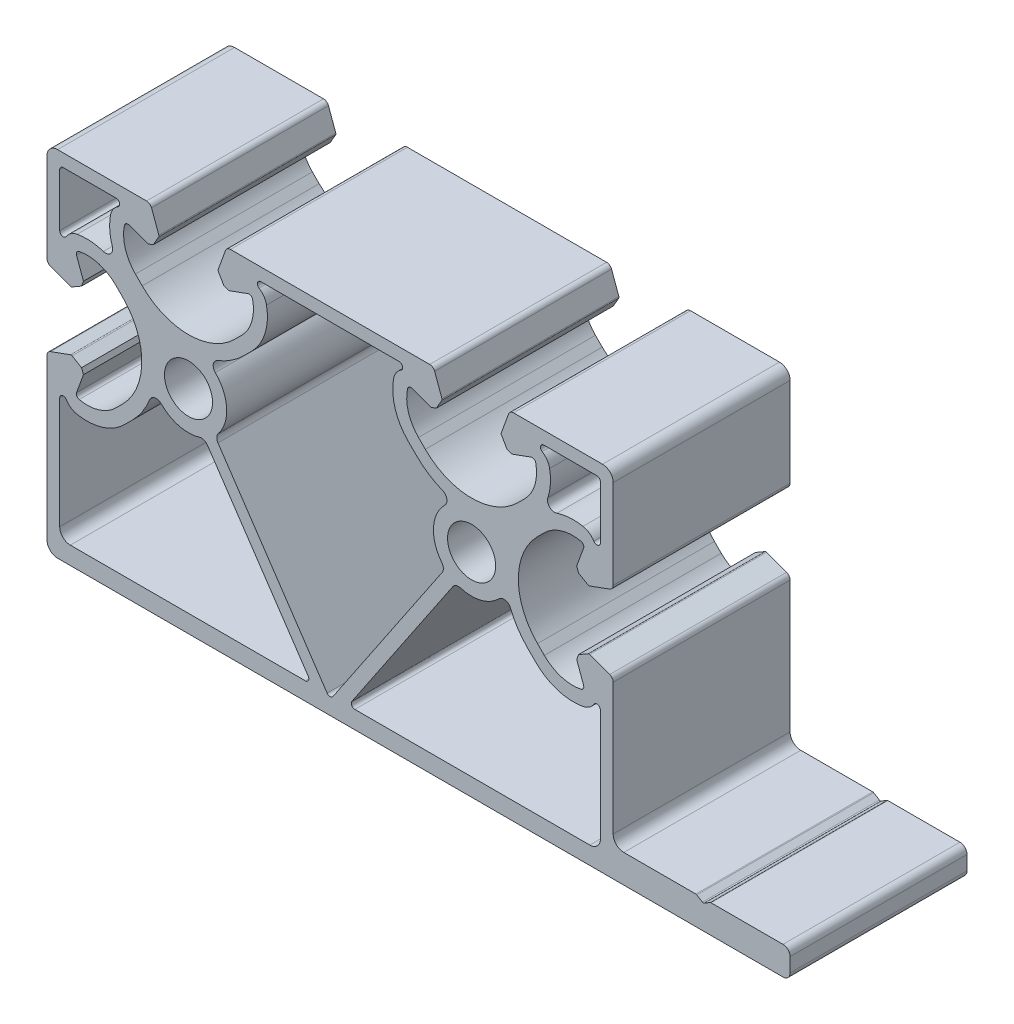
from build123d import *

# Parameters (mm, degrees)
SK_MAIN_EXTRUSION_R  = 3.4
MAIN_EXTRUSION_DEPTH = 25


with BuildPart() as part:
    # Sk Main Extrusion → Main Extrusion (new body)
    with BuildSketch(Plane.XY):
        with BuildLine():
            Line((-36.671180212, 25.809923155), (-39.506515107, 24.777945649))
            ThreePointArc((-39.506515107, 24.777945649), (-39.864364033, 24.503358511), (-40, 24.073176184))
            Line((-40, 24.073176184), (-40, 1.5))
            ThreePointArc((-40, 1.5), (-39.560660172, 0.439339828), (-38.5, 0))
            Line((-38.5, 0), (64, 0))
            ThreePointArc((64, 0), (64.707106781, 0.292893219), (65, 1))
            Line((65, 1), (65, 3))
            ThreePointArc((65, 3), (64.707106781, 3.707106781), (64, 4))
            Line((64, 4), (53.820658782, 4))
            ThreePointArc((53.820658782, 4), (53.753849188, 3.990907613), (53.691899263, 3.964291825))
            Line((53.691899263, 3.964291825), (52.878759519, 3.475708175))
            ThreePointArc((52.878759519, 3.475708175), (52.75, 3.44), (52.621240481, 3.475708175))
            Line((52.621240481, 3.475708175), (51.808100737, 3.964291825))
            ThreePointArc((51.808100737, 3.964291825), (51.746150812, 3.990907613), (51.679341218, 4))
            Line((51.679341218, 4), (41.5, 4))
            ThreePointArc((41.5, 4), (40.439339828, 4.439339828), (40, 5.5))
            Line((40, 5.5), (40, 24.073176184))
            ThreePointArc((40, 24.073176184), (39.864364033, 24.503358511), (39.506515107, 24.777945649))
            Line((39.506515107, 24.777945649), (36.671180212, 25.809923155))
            ThreePointArc((36.671180212, 25.809923155), (36.563886241, 25.824048675), (36.460675177, 25.791506351))
            Line((36.460675177, 25.791506351), (35.111296024, 25.012441934))
            Line((35.111296024, 25.012441934), (34.845251581, 24.281490834))
            Line((34.845251581, 24.281490834), (35.81984631, 21.603813821))
            ThreePointArc((35.81984631, 21.603813821), (35.786489799, 21.188925388), (35.450654467, 20.943039849))
            ThreePointArc((35.450654467, 20.943039849), (32.665882372, 21.066566987), (30.272684887, 22.495839661))
            Line((30.272684887, 22.495839661), (29.309262274, 23.459262274))
            ThreePointArc((29.309262274, 23.459262274), (26.6, 30), (29.309262274, 36.540737726))
            Line((29.309262274, 36.540737726), (30.272684887, 37.504160339))
            ThreePointArc((30.272684887, 37.504160339), (32.665882372, 38.933433013), (35.450654467, 39.056960151))
            ThreePointArc((35.450654467, 39.056960151), (35.786489799, 38.811074612), (35.81984631, 38.396186179))
            Line((35.81984631, 38.396186179), (34.845251581, 35.718509166))
            Line((34.845251581, 35.718509166), (35.111296024, 34.987558066))
            Line((35.111296024, 34.987558066), (36.460675177, 34.208493649))
            ThreePointArc((36.460675177, 34.208493649), (36.563886241, 34.175951325), (36.671180212, 34.190076845))
            Line((36.671180212, 34.190076845), (39.506515107, 35.222054351))
            ThreePointArc((39.506515107, 35.222054351), (39.864364033, 35.496641489), (40, 35.926823816))
            Line((40, 35.926823816), (40, 48.5))
            ThreePointArc((40, 48.5), (39.560660172, 49.560660172), (38.5, 50))
            Line((38.5, 50), (25.926823816, 50))
            ThreePointArc((25.926823816, 50), (25.496641489, 49.864364033), (25.222054351, 49.506515107))
            Line((25.222054351, 49.506515107), (24.190076845, 46.671180212))
            ThreePointArc((24.190076845, 46.671180212), (24.175951325, 46.563886241), (24.208493649, 46.460675177))
            Line((24.208493649, 46.460675177), (24.987558066, 45.111296024))
            Line((24.987558066, 45.111296024), (25.718509166, 44.845251581))
            Line((25.718509166, 44.845251581), (28.396186179, 45.81984631))
            ThreePointArc((28.396186179, 45.81984631), (28.811074612, 45.786489799), (29.056960151, 45.450654467))
            ThreePointArc((29.056960151, 45.450654467), (28.933433013, 42.665882372), (27.504160339, 40.272684887))
            Line((27.504160339, 40.272684887), (26.540737726, 39.309262274))
            ThreePointArc((26.540737726, 39.309262274), (20, 36.6), (13.459262274, 39.309262274))
            Line((13.459262274, 39.309262274), (12.495839661, 40.272684887))
            ThreePointArc((12.495839661, 40.272684887), (11.066566987, 42.665882372), (10.943039849, 45.450654467))
            ThreePointArc((10.943039849, 45.450654467), (11.188925388, 45.786489799), (11.603813821, 45.81984631))
            Line((11.603813821, 45.81984631), (14.281490834, 44.845251581))
            Line((14.281490834, 44.845251581), (15.012441934, 45.111296024))
            Line((15.012441934, 45.111296024), (15.791506351, 46.460675177))
            ThreePointArc((15.791506351, 46.460675177), (15.824048675, 46.563886241), (15.809923155, 46.671180212))
            Line((15.809923155, 46.671180212), (14.777945649, 49.506515107))
            ThreePointArc((14.777945649, 49.506515107), (14.503358511, 49.864364033), (14.073176184, 50))
            Line((14.073176184, 50), (-14.073176184, 50))
            ThreePointArc((-14.073176184, 50), (-14.503358511, 49.864364033), (-14.777945649, 49.506515107))
            Line((-14.777945649, 49.506515107), (-15.809923155, 46.671180212))
            ThreePointArc((-15.809923155, 46.671180212), (-15.824048675, 46.563886241), (-15.791506351, 46.460675177))
            Line((-15.791506351, 46.460675177), (-15.012441934, 45.111296024))
            Line((-15.012441934, 45.111296024), (-14.281490834, 44.845251581))
            Line((-14.281490834, 44.845251581), (-11.603813821, 45.81984631))
            ThreePointArc((-11.603813821, 45.81984631), (-11.188925388, 45.786489799), (-10.943039849, 45.450654467))
            ThreePointArc((-10.943039849, 45.450654467), (-11.066566987, 42.665882372), (-12.495839661, 40.272684887))
            Line((-12.495839661, 40.272684887), (-13.459262274, 39.309262274))
            ThreePointArc((-13.459262274, 39.309262274), (-20, 36.6), (-26.540737726, 39.309262274))
            Line((-26.540737726, 39.309262274), (-27.504160339, 40.272684887))
            ThreePointArc((-27.504160339, 40.272684887), (-28.933433013, 42.665882372), (-29.056960151, 45.450654467))
            ThreePointArc((-29.056960151, 45.450654467), (-28.811074612, 45.786489799), (-28.396186179, 45.81984631))
            Line((-28.396186179, 45.81984631), (-25.718509166, 44.845251581))
            Line((-25.718509166, 44.845251581), (-24.987558066, 45.111296024))
            Line((-24.987558066, 45.111296024), (-24.208493649, 46.460675177))
            ThreePointArc((-24.208493649, 46.460675177), (-24.175951325, 46.563886241), (-24.190076845, 46.671180212))
            Line((-24.190076845, 46.671180212), (-25.222054351, 49.506515107))
            ThreePointArc((-25.222054351, 49.506515107), (-25.496641489, 49.864364033), (-25.926823816, 50))
            Line((-25.926823816, 50), (-38.5, 50))
            ThreePointArc((-38.5, 50), (-39.560660172, 49.560660172), (-40, 48.5))
            Line((-40, 48.5), (-40, 35.926823816))
            ThreePointArc((-40, 35.926823816), (-39.864364033, 35.496641489), (-39.506515107, 35.222054351))
            Line((-39.506515107, 35.222054351), (-36.671180212, 34.190076845))
            ThreePointArc((-36.671180212, 34.190076845), (-36.563886241, 34.175951325), (-36.460675177, 34.208493649))
            Line((-36.460675177, 34.208493649), (-35.111296024, 34.987558066))
            Line((-35.111296024, 34.987558066), (-34.845251581, 35.718509166))
            Line((-34.845251581, 35.718509166), (-35.81984631, 38.396186179))
            ThreePointArc((-35.81984631, 38.396186179), (-35.786489799, 38.811074612), (-35.450654467, 39.056960151))
            ThreePointArc((-35.450654467, 39.056960151), (-32.665882372, 38.933433013), (-30.272684887, 37.504160339))
            Line((-30.272684887, 37.504160339), (-29.309262274, 36.540737726))
            ThreePointArc((-29.309262274, 36.540737726), (-26.6, 30), (-29.309262274, 23.459262274))
            Line((-29.309262274, 23.459262274), (-30.272684887, 22.495839661))
            ThreePointArc((-30.272684887, 22.495839661), (-32.665882372, 21.066566987), (-35.450654467, 20.943039849))
            ThreePointArc((-35.450654467, 20.943039849), (-35.786489799, 21.188925388), (-35.81984631, 21.603813821))
            Line((-35.81984631, 21.603813821), (-34.845251581, 24.281490834))
            Line((-34.845251581, 24.281490834), (-35.111296024, 25.012441934))
            Line((-35.111296024, 25.012441934), (-36.460675177, 25.791506351))
            ThreePointArc((-36.460675177, 25.791506351), (-36.563886241, 25.824048675), (-36.671180212, 25.809923155))
        make_face()
        with Locations((-20, 30)):
            Circle(SK_MAIN_EXTRUSION_R, mode=Mode.SUBTRACT)
        with Locations((20, 30)):
            Circle(SK_MAIN_EXTRUSION_R, mode=Mode.SUBTRACT)
        with BuildLine():
            Line((-11.050692158, 39.072247978), (-12.186470068, 37.936470068))
            ThreePointArc((-12.186470068, 37.936470068), (-13.91310246, 36.527626209), (-15.887298534, 35.493870777))
            ThreePointArc((-15.887298534, 35.493870777), (-16.495658662, 34.761982205), (-16.215872675, 33.852321429))
            ThreePointArc((-16.215872675, 33.852321429), (-14.60935752, 30.317763511), (-15.789484825, 26.618940704))
            ThreePointArc((-15.789484825, 26.618940704), (-16.008882919, 26.034687218), (-15.839134884, 25.434126427))
            Line((-15.839134884, 25.434126427), (-0.414687546, 2.53662982))
            ThreePointArc((-0.414687546, 2.53662982), (0, 2.315975913), (0.414687546, 2.53662982))
            Line((0.414687546, 2.53662982), (15.839134884, 25.434126427))
            ThreePointArc((15.839134884, 25.434126427), (16.008882919, 26.034687218), (15.789484825, 26.618940704))
            ThreePointArc((15.789484825, 26.618940704), (14.60935752, 30.317763511), (16.215872675, 33.852321429))
            ThreePointArc((16.215872675, 33.852321429), (16.495658662, 34.761982205), (15.887298534, 35.493870777))
            ThreePointArc((15.887298534, 35.493870777), (13.91310246, 36.527626209), (12.186470068, 37.936470068))
            Line((12.186470068, 37.936470068), (11.050692158, 39.072247978))
            ThreePointArc((11.050692158, 39.072247978), (9.192033971, 42.149264347), (8.978734334, 45.737738015))
            ThreePointArc((8.978734334, 45.737738015), (9.341315508, 46.617371566), (10.028880148, 47.275))
            ThreePointArc((10.028880148, 47.275), (10.246373406, 47.836930639), (9.765488804, 48.2))
            Line((9.765488804, 48.2), (-9.765488804, 48.2))
            ThreePointArc((-9.765488804, 48.2), (-10.246373406, 47.836930639), (-10.028880148, 47.275))
            ThreePointArc((-10.028880148, 47.275), (-9.341315508, 46.617371566), (-8.978734334, 45.737738015))
            ThreePointArc((-8.978734334, 45.737738015), (-9.192033971, 42.149264347), (-11.050692158, 39.072247978))
        make_face(mode=Mode.SUBTRACT)
        with BuildLine():
            Line((-27.936470068, 22.186470068), (-29.072247978, 21.050692158))
            ThreePointArc((-29.072247978, 21.050692158), (-32.149264347, 19.192033971), (-35.737738015, 18.978734334))
            ThreePointArc((-35.737738015, 18.978734334), (-36.617371566, 19.341315508), (-37.275, 20.028880148))
            ThreePointArc((-37.275, 20.028880148), (-37.836930639, 20.246373406), (-38.2, 19.765488804))
            Line((-38.2, 19.765488804), (-38.2, 4))
            ThreePointArc((-38.2, 4), (-37.760660172, 2.939339828), (-36.7, 2.5))
            Line((-36.7, 2.5), (-3.5, 2.5))
            ThreePointArc((-3.5, 2.5), (-3.058597097, 2.765130937), (-3.085312454, 3.279346093))
            Line((-3.085312454, 3.279346093), (-17.332010049, 24.428480493))
            ThreePointArc((-17.332010049, 24.428480493), (-17.824789446, 24.811437573), (-18.448668712, 24.827633884))
            ThreePointArc((-18.448668712, 24.827633884), (-21.343666864, 24.769841364), (-23.852321429, 26.215872675))
            ThreePointArc((-23.852321429, 26.215872675), (-24.761982205, 26.495658662), (-25.493870777, 25.887298534))
            ThreePointArc((-25.493870777, 25.887298534), (-26.527626209, 23.91310246), (-27.936470068, 22.186470068))
        make_face(mode=Mode.SUBTRACT)
        with BuildLine():
            Line((-38.2, 47.7), (-38.2, 40.234511196))
            ThreePointArc((-38.2, 40.234511196), (-37.836930639, 39.753626594), (-37.275, 39.971119852))
            ThreePointArc((-37.275, 39.971119852), (-36.617371566, 40.658684492), (-35.737738015, 41.021265666))
            ThreePointArc((-35.737738015, 41.021265666), (-33.869688502, 41.128927892), (-32.033125537, 40.770826496))
            ThreePointArc((-32.033125537, 40.770826496), (-31.01369565, 41.01369565), (-30.770826496, 42.033125537))
            ThreePointArc((-30.770826496, 42.033125537), (-31.128927892, 43.869688502), (-31.021265666, 45.737738015))
            ThreePointArc((-31.021265666, 45.737738015), (-30.658684492, 46.617371566), (-29.971119852, 47.275))
            ThreePointArc((-29.971119852, 47.275), (-29.753626594, 47.836930639), (-30.234511196, 48.2))
            Line((-30.234511196, 48.2), (-37.7, 48.2))
            ThreePointArc((-37.7, 48.2), (-38.053553391, 48.053553391), (-38.2, 47.7))
        make_face(mode=Mode.SUBTRACT)
        with BuildLine():
            Line((17.332010049, 24.428480493), (3.085312454, 3.279346093))
            ThreePointArc((3.085312454, 3.279346093), (3.058597097, 2.765130937), (3.5, 2.5))
            Line((3.5, 2.5), (36.7, 2.5))
            ThreePointArc((36.7, 2.5), (37.760660172, 2.939339828), (38.2, 4))
            Line((38.2, 4), (38.2, 19.765488804))
            ThreePointArc((38.2, 19.765488804), (37.836930639, 20.246373406), (37.275, 20.028880148))
            ThreePointArc((37.275, 20.028880148), (36.617371566, 19.341315508), (35.737738015, 18.978734334))
            ThreePointArc((35.737738015, 18.978734334), (32.149264347, 19.192033971), (29.072247978, 21.050692158))
            Line((29.072247978, 21.050692158), (27.936470068, 22.186470068))
            ThreePointArc((27.936470068, 22.186470068), (26.527626209, 23.91310246), (25.493870777, 25.887298534))
            ThreePointArc((25.493870777, 25.887298534), (24.761982205, 26.495658662), (23.852321429, 26.215872675))
            ThreePointArc((23.852321429, 26.215872675), (21.343666864, 24.769841364), (18.448668712, 24.827633884))
            ThreePointArc((18.448668712, 24.827633884), (17.824789446, 24.811437573), (17.332010049, 24.428480493))
        make_face(mode=Mode.SUBTRACT)
        with BuildLine():
            Line((38.2, 40.234511196), (38.2, 47.7))
            ThreePointArc((38.2, 47.7), (38.053553391, 48.053553391), (37.7, 48.2))
            Line((37.7, 48.2), (30.234511196, 48.2))
            ThreePointArc((30.234511196, 48.2), (29.753626594, 47.836930639), (29.971119852, 47.275))
            ThreePointArc((29.971119852, 47.275), (30.658684492, 46.617371566), (31.021265666, 45.737738015))
            ThreePointArc((31.021265666, 45.737738015), (31.128927892, 43.869688502), (30.770826496, 42.033125537))
            ThreePointArc((30.770826496, 42.033125537), (31.01369565, 41.01369565), (32.033125537, 40.770826496))
            ThreePointArc((32.033125537, 40.770826496), (33.869688502, 41.128927892), (35.737738015, 41.021265666))
            ThreePointArc((35.737738015, 41.021265666), (36.617371566, 40.658684492), (37.275, 39.971119852))
            ThreePointArc((37.275, 39.971119852), (37.836930639, 39.753626594), (38.2, 40.234511196))
        make_face(mode=Mode.SUBTRACT)
    extrude(amount=-MAIN_EXTRUSION_DEPTH)


solid = part.part
